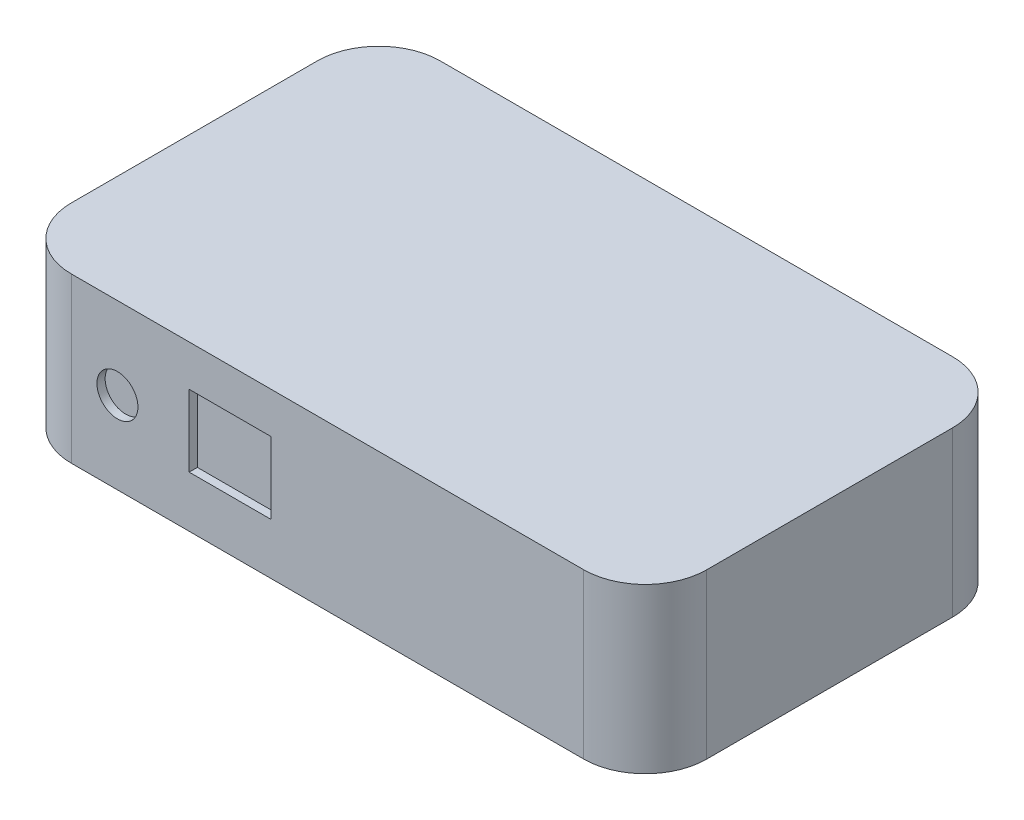
from build123d import *

# Parameters (mm, degrees)
SKETCH1_W           = 98.425
SKETCH1_H           = 57.15
BOSS_EXTRUDE1_DEPTH = 25.4
SKETCH2_W           = 5.08
SKETCH2_H           = 45.72
BOSS_EXTRUDE2_DEPTH = 0.762
FILLET1_R           = 9.525
SKETCH3_W           = 7.14375
SKETCH3_H           = 14.2875
CUT_EXTRUDE1_DEPTH  = 1.27
SKETCH4_R           = 3.175
SKETCH4_W           = 12.7
SKETCH4_H           = 11.1125
CUT_EXTRUDE2_DEPTH  = 1.27


with BuildPart() as part:
    # Sketch1 → Boss-Extrude1 (new body)
    with BuildSketch(Plane(origin=(0, 0, 0), x_dir=(1, 0, 0), z_dir=(0, 1, 0))):
        Rectangle(SKETCH1_W, SKETCH1_H)
    extrude(amount=BOSS_EXTRUDE1_DEPTH)

    # Sketch2 → Boss-Extrude2 (add)
    with BuildSketch(Plane.XZ):
        with Locations((-40.3225, 0)):
            Rectangle(SKETCH2_W, SKETCH2_H)
        with Locations((40.3225, 0)):
            Rectangle(SKETCH2_W, SKETCH2_H)
    extrude(amount=BOSS_EXTRUDE2_DEPTH)

    # Fillet1
    fillet1_edges = [part.edges().sort_by_distance(p)[0] for p in [
        (-49.2125, 12.7, -28.575),
        (49.2125, 12.7, -28.575),
        (49.2125, 12.7, 28.575),
        (-49.2125, 12.7, 28.575),
    ]]
    fillet(fillet1_edges, radius=FILLET1_R)

    # Sketch3 → Cut-Extrude1 (cut)
    with BuildSketch(Plane(origin=(0, 0, -28.575), x_dir=(-1, 0, 0), z_dir=(0, 0, -1))):
        with Locations((-34.528125, 15.08125)):
            Rectangle(SKETCH3_W, SKETCH3_H)
        with Locations((-23.01875, 15.08125)):
            Rectangle(SKETCH3_W, SKETCH3_H)
        with Locations((-11.509375, 15.08125)):
            Rectangle(SKETCH3_W, SKETCH3_H)
        with Locations((0, 15.08125)):
            Rectangle(SKETCH3_W, SKETCH3_H)
        with Locations((11.509375, 15.08125)):
            Rectangle(SKETCH3_W, SKETCH3_H)
        with Locations((23.01875, 15.08125)):
            Rectangle(SKETCH3_W, SKETCH3_H)
        with Locations((34.528125, 15.08125)):
            Rectangle(SKETCH3_W, SKETCH3_H)
    extrude(amount=-CUT_EXTRUDE1_DEPTH, mode=Mode.SUBTRACT)

    # Sketch4 → Cut-Extrude2 (cut)
    with BuildSketch(Plane.XY.offset(28.575)):
        with Locations((-32.54375, 12.7)):
            Circle(SKETCH4_R)
        with Locations((-15.08125, 13.49375)):
            Rectangle(SKETCH4_W, SKETCH4_H)
    extrude(amount=-CUT_EXTRUDE2_DEPTH, mode=Mode.SUBTRACT)


solid = part.part
